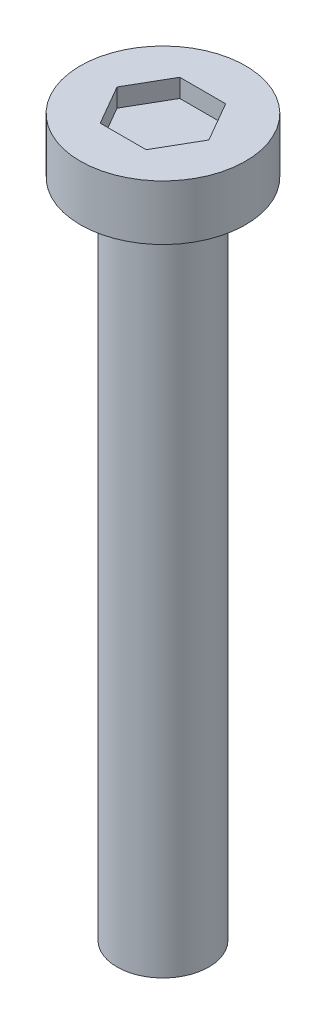
from build123d import *

# Parameters (mm, degrees)
SKETCH1_R           = 1.25
BOSS_EXTRUDE1_DEPTH = 18
SKETCH4_R           = 2.25
BOSS_EXTRUDE2_DEPTH = 1.5
CUT_EXTRUDE1_DEPTH  = 0.5


with BuildPart() as part:
    # Sketch1 → Boss-Extrude1 (new body)
    with BuildSketch(Plane(origin=(0, 0, 0), x_dir=(1, 0, 0), z_dir=(0, 1, 0))):
        Circle(SKETCH1_R)
    extrude(amount=BOSS_EXTRUDE1_DEPTH)

    # Sketch4 → Boss-Extrude2 (add)
    with BuildSketch(Plane(origin=(0, 18, 0), x_dir=(1, 0, 0), z_dir=(0, 1, 0))):
        Circle(SKETCH4_R)
    extrude(amount=BOSS_EXTRUDE2_DEPTH)

    # Sketch5 → Cut-Extrude1 (cut)
    with BuildSketch(Plane(origin=(0, 19.5, 0), x_dir=(1, 0, 0), z_dir=(0, 1, 0))):
        Polygon((1.25, 0), (0.625, 1.082531755), (-0.625, 1.082531755), (-1.25, 0), (-0.625, -1.082531755), (0.625, -1.082531755), align=None)
    extrude(amount=-CUT_EXTRUDE1_DEPTH, mode=Mode.SUBTRACT)


solid = part.part
